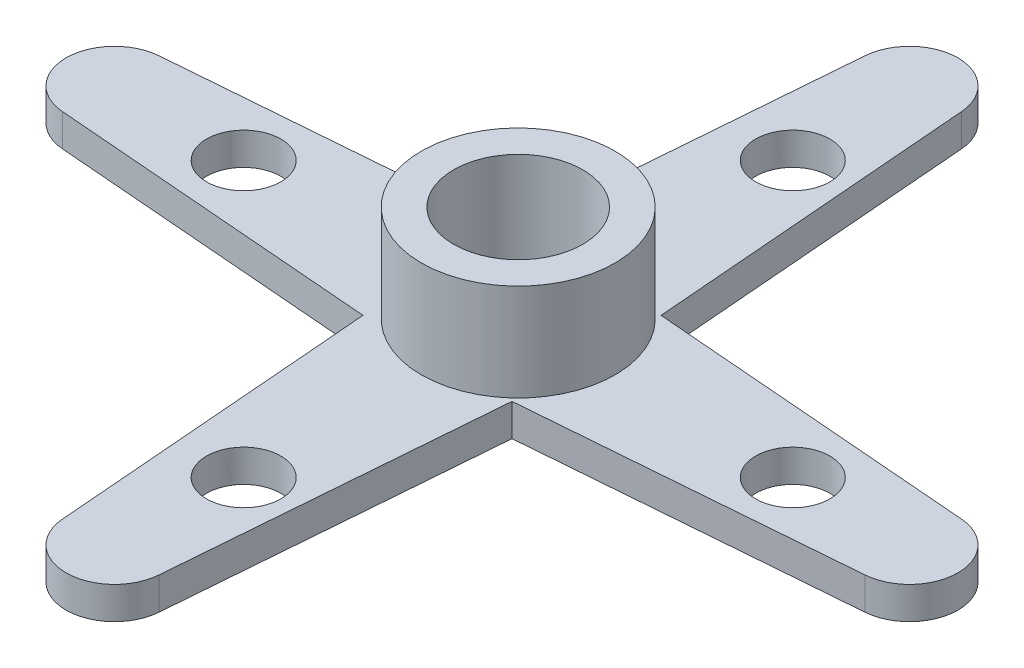
from build123d import *

# Parameters (mm, degrees)
SKICA1_R                 = 2
P_IDAT_VYSUNUT_M1_DEPTH  = 1
SKICA2_R                 = 1.15
ODEBRAT_VYSUNUT_M1_DEPTH = 2
SKICA3_R                 = 3
SKICA3_R_2               = 2
P_IDAT_VYSUNUT_M2_DEPTH  = 3
KRUHOV_POLE1_COUNT       = 4


with BuildPart() as part:
    # Skica1 → Přidat vysunutím1 (new body)
    with BuildSketch(Plane(origin=(0, 0, 0), x_dir=(1, 0, 0), z_dir=(0, 1, 0))):
        with BuildLine():
            Line((-12.62, 1.495192295), (-2.5, 2.307395517))
            Line((-2.5, 2.307395517), (-1.687796778, 12.427395517))
            ThreePointArc((-1.687796778, 12.427395517), (-0.192604483, 13.807395517), (1.302587813, 12.427395517))
            Line((1.302587813, 12.427395517), (2.114791035, 2.307395517))
            Line((2.114791035, 2.307395517), (12.234791035, 1.495192295))
            ThreePointArc((12.234791035, 1.495192295), (13.614791035, 0), (12.234791035, -1.495192295))
            Line((12.234791035, -1.495192295), (2.114791035, -2.307395517))
            Line((2.114791035, -2.307395517), (1.302587813, -12.427395517))
            ThreePointArc((1.302587813, -12.427395517), (-0.192604483, -13.807395517), (-1.687796778, -12.427395517))
            Line((-1.687796778, -12.427395517), (-2.5, -2.307395517))
            Line((-2.5, -2.307395517), (-12.62, -1.495192295))
            ThreePointArc((-12.62, -1.495192295), (-14, 0), (-12.62, 1.495192295))
        make_face()
        Circle(SKICA1_R, mode=Mode.SUBTRACT)
    extrude(amount=P_IDAT_VYSUNUT_M1_DEPTH)

    # Skica2 → Odebrat vysunutím1 (cut)
    with BuildSketch(Plane(origin=(0, 1, 0), x_dir=(1, 0, 0), z_dir=(0, 1, 0))):
        with Locations((-8.5, 0)):
            Circle(SKICA2_R)
        with Locations((8.5, 0)):
            Circle(SKICA2_R)
    odebrat_vysunut_m1 = extrude(amount=-ODEBRAT_VYSUNUT_M1_DEPTH, mode=Mode.SUBTRACT)

    # Skica3 → Přidat vysunutím2 (add)
    with BuildSketch(Plane(origin=(0, 1, 0), x_dir=(1, 0, 0), z_dir=(0, 1, 0))):
        Circle(SKICA3_R)
        Circle(SKICA3_R_2, mode=Mode.SUBTRACT)
    extrude(amount=P_IDAT_VYSUNUT_M2_DEPTH)

    # Kruhové pole1: Odebrat vysunutím1 ×4 about axis
    kruhov_pole1_axis = Axis((0, 0, 0), (0, 1, 0))
    for i in range(1, KRUHOV_POLE1_COUNT):
        add(odebrat_vysunut_m1.rotate(kruhov_pole1_axis, i * 360 / KRUHOV_POLE1_COUNT), mode=Mode.SUBTRACT)


solid = part.part
